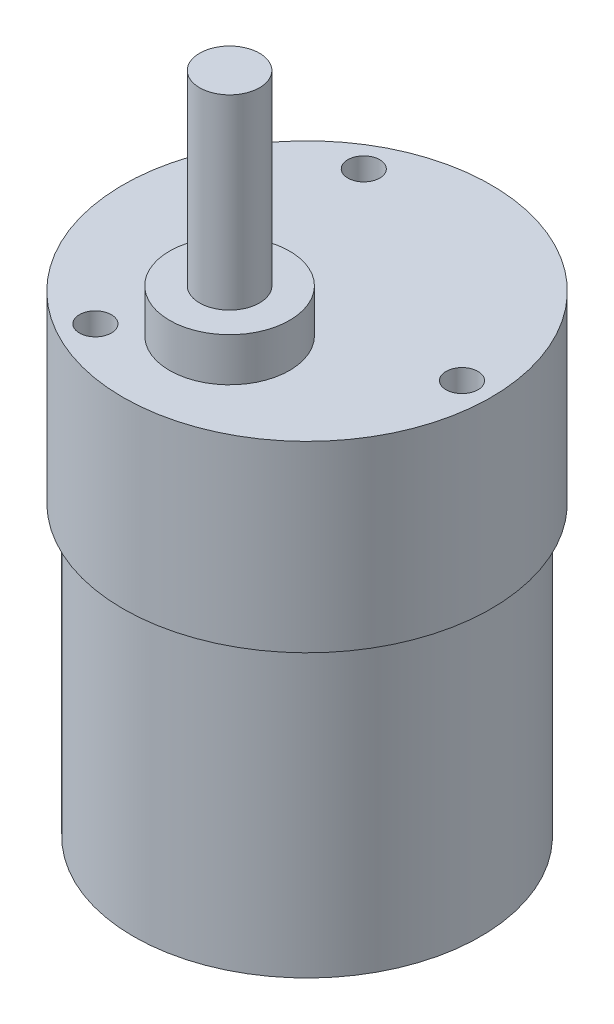
from build123d import *

# Parameters (mm, degrees)
SKETCH1_R           = 17.2593
BOSS_EXTRUDE1_DEPTH = 28.7528
SKETCH2_R           = 18.30705
BOSS_EXTRUDE2_DEPTH = 18.2118
SKETCH3_R           = 1.5875
CUT_EXTRUDE1_DEPTH  = 12.7
SKETCH4_R           = 5.969
BOSS_EXTRUDE3_DEPTH = 4.318
SKETCH5_R           = 2.97815
BOSS_EXTRUDE4_DEPTH = 18.542


with BuildPart() as part:
    # Sketch1 → Boss-Extrude1 (new body)
    with BuildSketch(Plane(origin=(0, 0, 0), x_dir=(1, 0, 0), z_dir=(0, 1, 0))):
        with Locations(Location((0, 0, 0), (0, 0, 270))):  # turned: the seam where the file's is
            Circle(SKETCH1_R)
    extrude(amount=BOSS_EXTRUDE1_DEPTH)

    # Sketch2 → Boss-Extrude2 (add)
    with BuildSketch(Plane(origin=(0, 28.7528, 0), x_dir=(1, 0, 0), z_dir=(0, 1, 0))):
        with Locations(Location((0, 0, 0), (0, 0, 270))):  # turned: the seam where the file's is
            Circle(SKETCH2_R)
    extrude(amount=BOSS_EXTRUDE2_DEPTH)

    # Sketch3 → Cut-Extrude1 (cut)
    with BuildSketch(Plane(origin=(0, 46.9646, 0), x_dir=(1, 0, 0), z_dir=(0, 1, 0))):
        with Locations(Location((-7.706298188, -13.3477, 0), (0, 0, 270))):  # turned: the seam where the file's is
            Circle(SKETCH3_R)
        with Locations(Location((-7.706298188, 13.3477, 0), (0, 0, 270))):  # turned: the seam where the file's is
            Circle(SKETCH3_R)
        with Locations(Location((15.412596376, 0, 0), (0, 0, 270))):  # turned: the seam where the file's is
            Circle(SKETCH3_R)
    extrude(amount=-CUT_EXTRUDE1_DEPTH, mode=Mode.SUBTRACT)

    # Sketch4 → Boss-Extrude3 (add)
    with BuildSketch(Plane(origin=(0, 46.9646, 0), x_dir=(1, 0, 0), z_dir=(0, 1, 0))):
        with Locations(Location((0, -7.706298188, 0), (0, 0, 270))):  # turned: the seam where the file's is
            Circle(SKETCH4_R)
    extrude(amount=BOSS_EXTRUDE3_DEPTH)

    # Sketch5 → Boss-Extrude4 (add)
    with BuildSketch(Plane(origin=(0, 51.2826, 0), x_dir=(1, 0, 0), z_dir=(0, 1, 0))):
        with Locations(Location((0, -7.706298188, 0), (0, 0, 270))):  # turned: the seam where the file's is
            Circle(SKETCH5_R)
    extrude(amount=BOSS_EXTRUDE4_DEPTH)


solid = part.part
